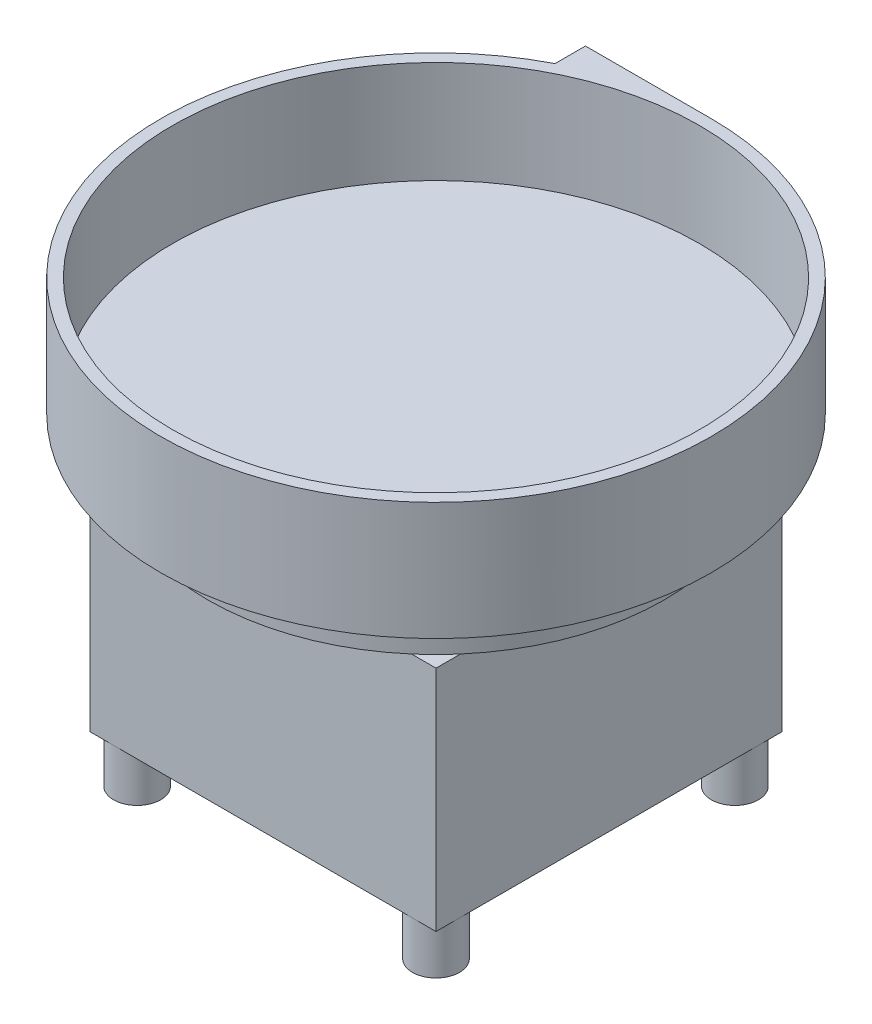
from build123d import *

# Parameters (mm, degrees)
SKETCH1_R           = 212.725
BOSS_EXTRUDE1_DEPTH = 82.55
SKETCH2_R           = 222.25
BOSS_EXTRUDE2_DEPTH = 12.7
SKETCH3_R           = 184.15
BOSS_EXTRUDE3_DEPTH = 38.1
SKETCH4_W           = 279.4
SKETCH4_H           = 279.4
BOSS_EXTRUDE4_DEPTH = 184.15
SKETCH5_R           = 19.05
BOSS_EXTRUDE5_DEPTH = 38.1


with BuildPart() as part:
    # Sketch1 → Boss-Extrude1 (new body)
    with BuildSketch(Plane(origin=(0, 0, 0), x_dir=(1, 0, 0), z_dir=(0, 1, 0))):
        with BuildLine():
            Line((0, 222.25), (-101.6, 222.25))
            Line((-101.6, 222.25), (-101.6, 197.667657))
            ThreePointArc((-101.6, 197.667657), (52.265791, -216.017012), (0, 222.25))
        make_face()
        Circle(SKETCH1_R, mode=Mode.SUBTRACT)
    extrude(amount=BOSS_EXTRUDE1_DEPTH)

    # Sketch2 → Boss-Extrude2 (add)
    with BuildSketch(Plane.XZ):
        Circle(SKETCH2_R)
    extrude(amount=BOSS_EXTRUDE2_DEPTH)

    # Sketch3 → Boss-Extrude3 (add)
    with BuildSketch(Plane.XZ.offset(12.7)):
        Circle(SKETCH3_R)
    extrude(amount=BOSS_EXTRUDE3_DEPTH)

    # Sketch4 → Boss-Extrude4 (add)
    with BuildSketch(Plane.XZ.offset(50.8)):
        Rectangle(SKETCH4_W, SKETCH4_H)
    extrude(amount=BOSS_EXTRUDE4_DEPTH)

    # Sketch5 → Boss-Extrude5 (add)
    with BuildSketch(Plane.XZ.offset(234.95)):
        with Locations((-120.65, -120.65)):
            Circle(SKETCH5_R)
        with Locations((-120.65, 120.65)):
            Circle(SKETCH5_R)
        with Locations((120.65, -120.65)):
            Circle(SKETCH5_R)
        with Locations((120.65, 120.65)):
            Circle(SKETCH5_R)
    extrude(amount=BOSS_EXTRUDE5_DEPTH)


solid = part.part
